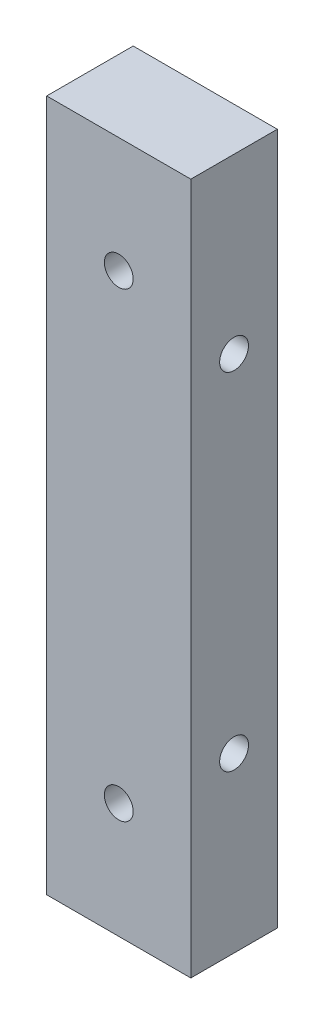
from build123d import *

# Parameters (mm, degrees)
SKETCH1_W           = 25
SKETCH1_H           = 15
BOSS_EXTRUDE1_DEPTH = 60
M6_TAPPED_HOLE1_D   = 5
M6_TAPPED_HOLE2_D   = 5


with BuildPart() as part:
    # Sketch1 → Boss-Extrude1 (new body, symmetric)
    with BuildSketch(Plane(origin=(0, 0, 0), x_dir=(1, 0, 0), z_dir=(0, 1, 0))):
        Rectangle(SKETCH1_W, SKETCH1_H)
    extrude(amount=BOSS_EXTRUDE1_DEPTH, both=True)

    # M6 Tapped Hole1 (through all)
    with Locations(Plane.ZY.offset(12.5)):
        with Locations((0, 30), (0, -30)):
            Hole(M6_TAPPED_HOLE1_D / 2)

    # M6 Tapped Hole2 (through all)
    with Locations(Plane.XY.offset(7.5)):
        with Locations((0, 40), (0, -40)):
            Hole(M6_TAPPED_HOLE2_D / 2)


solid = part.part
